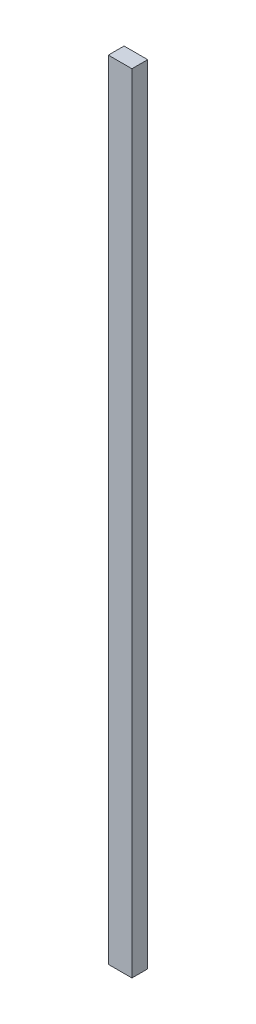
from build123d import *

# Parameters (mm, degrees)
SKETCH1_W           = 12
SKETCH1_H           = 8
BOSS_EXTRUDE1_DEPTH = 400


with BuildPart() as part:
    # Sketch1 → Boss-Extrude1 (new body)
    with BuildSketch(Plane(origin=(0, 0, 0), x_dir=(1, 0, 0), z_dir=(0, 1, 0))):
        Rectangle(SKETCH1_W, SKETCH1_H)
    extrude(amount=BOSS_EXTRUDE1_DEPTH)


solid = part.part
